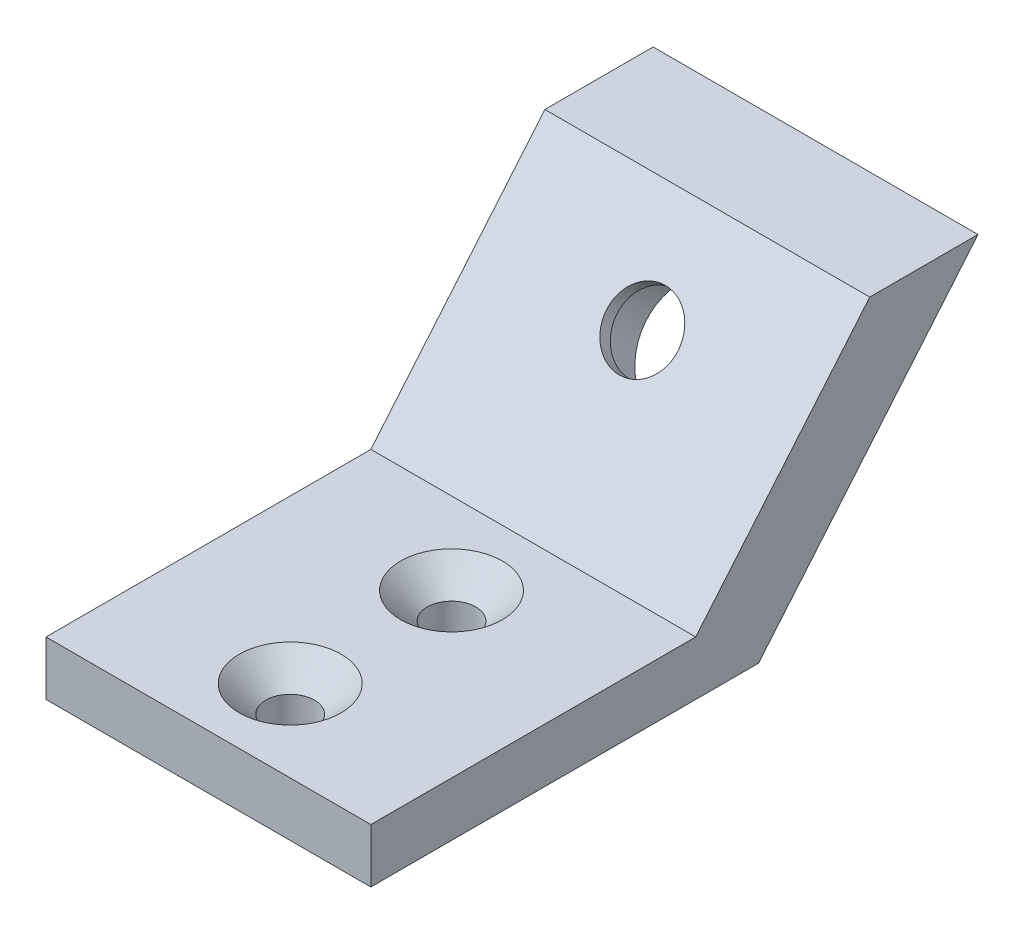
from build123d import *

# Parameters (mm, degrees)
SKETCH1_W                                           = 30
SKETCH1_H                                           = 5
BOSS_EXTRUDE1_DEPTH                                 = 30
BOSS_EXTRUDE3_DEPTH                                 = 30
CSK_FOR_M4_COUNTERSUNK_FLAT_HEAD_SCREW1_D           = 4.5
CSK_FOR_M4_COUNTERSUNK_FLAT_HEAD_SCREW1_CSINK_D     = 9.4
CSK_FOR_M4_COUNTERSUNK_FLAT_HEAD_SCREW1_CSINK_ANGLE = 90


with BuildPart() as part:
    # Sketch1 → Boss-Extrude1 (new body)
    with BuildSketch(Plane.XY):
        with Locations((0, -2.5)):
            Rectangle(SKETCH1_W, SKETCH1_H)
    extrude(amount=BOSS_EXTRUDE1_DEPTH)

    # Sketch3 → Boss-Extrude3 (add)
    with BuildSketch(Plane(origin=(15, 0, 0), x_dir=(0, 0, -1), z_dir=(1, 0, 0))):
        Polygon((0, 0), (16.069690242, 19.151111078), (26.069690242, 19.151111078), (5.804501844, -5), (0, -5), align=None)
    extrude(amount=-BOSS_EXTRUDE3_DEPTH)

    # Sketch6 → CBORE for M6 Hex Socket Head Cap Screw1 (revolve, cut)
    with BuildSketch(Plane(origin=(0, 7.075555539, -15.937096043), x_dir=(0, 0.766044443, -0.64278761), z_dir=(1, 0, 0))):
        Polygon((0, 0), (0, 42.951874637), (3.3, 42.951874637), (3.3, 6.4), (5.5, 6.4), (5.5, 0.025), (5.525, 0), align=None)
    revolve(axis=Axis((0, 2.993854217, -20.801478257), (0, 0.64278761, 0.766044443)), mode=Mode.SUBTRACT)

    # CSK for M4 Countersunk Flat Head Screw1 (through all)
    with Locations(Plane(origin=(0, 0, 0), x_dir=(1, 0, 0), z_dir=(0, 1, 0))):
        with Locations((0, -7.55), (0, -22.45)):
            CounterSinkHole(CSK_FOR_M4_COUNTERSUNK_FLAT_HEAD_SCREW1_D / 2, CSK_FOR_M4_COUNTERSUNK_FLAT_HEAD_SCREW1_CSINK_D / 2, counter_sink_angle=CSK_FOR_M4_COUNTERSUNK_FLAT_HEAD_SCREW1_CSINK_ANGLE)


solid = part.part
